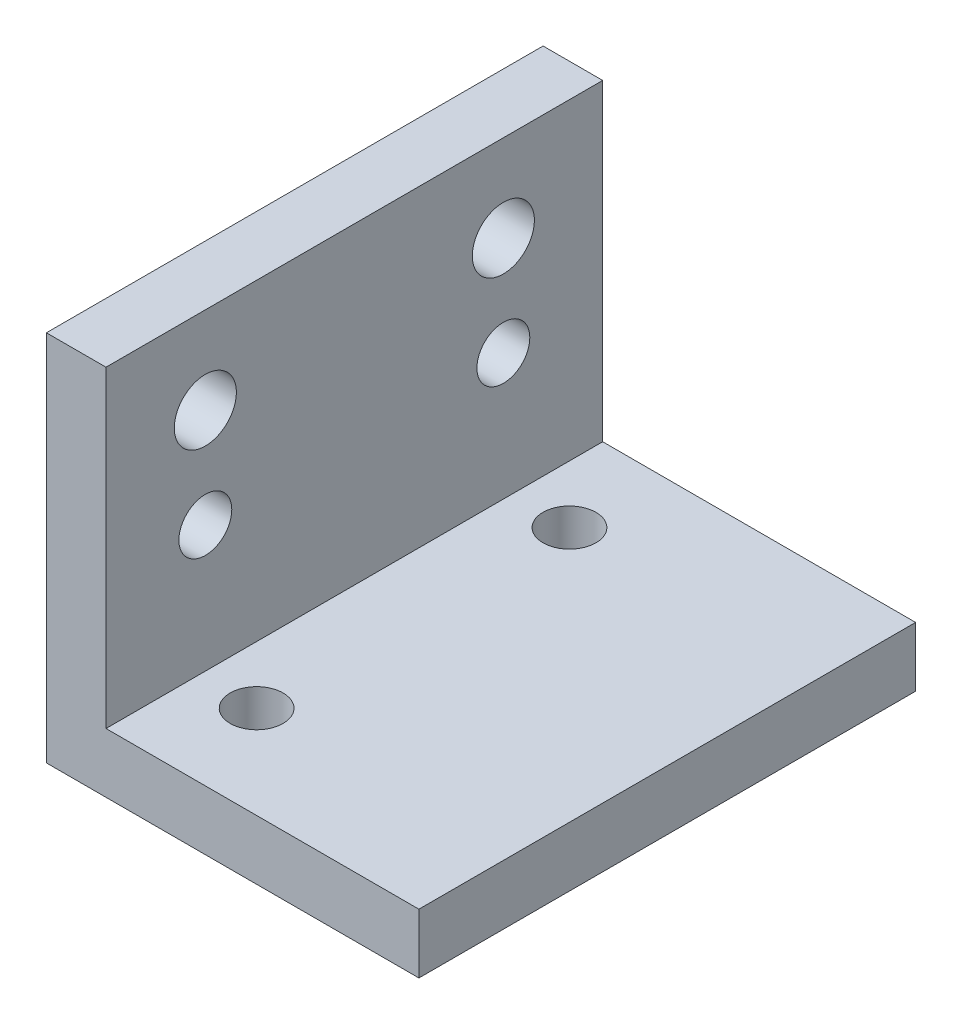
from build123d import *

# Parameters (mm, degrees)
BOSS_EXTRUDE1_DEPTH   = 25.4
F_6_32_TAPPED_HOLE1_D = 2.7051
F_6_32_TAPPED_HOLE2_D = 2.7051
SKETCH7_R             = 1.5875
CUT_EXTRUDE1_DEPTH    = 36.554556726


with BuildPart() as part:
    # Sketch1 → Boss-Extrude1 (new body)
    with BuildSketch(Plane.XY):
        Polygon((0, 0), (19.05, 0), (19.05, 3.048), (3.048, 3.048), (3.048, 19.05), (0, 19.05), align=None)
    extrude(amount=BOSS_EXTRUDE1_DEPTH)

    # 6-32 Tapped Hole1 (through all)
    with Locations(Plane(origin=(3.048, 0, 0), x_dir=(0, 0, -1), z_dir=(1, 0, 0))):
        with Locations((-20.32, 9.525), (-5.08, 9.525)):
            Hole(F_6_32_TAPPED_HOLE1_D / 2)

    # 6-32 Tapped Hole2 (through all)
    with Locations(Plane(origin=(0, 3.048, 0), x_dir=(1, 0, 0), z_dir=(0, 1, 0))):
        with Locations((6, -20.65), (6, -4.65)):
            Hole(F_6_32_TAPPED_HOLE2_D / 2)

    # Sketch7 → Cut-Extrude1 (cut, through all)
    with BuildSketch(Plane(origin=(3.048, 0, 0), x_dir=(0, 0, -1), z_dir=(1, 0, 0))):
        with Locations((-20.32, 14.605)):
            Circle(SKETCH7_R)
        with Locations((-5.08, 14.605)):
            Circle(SKETCH7_R)
    extrude(amount=-CUT_EXTRUDE1_DEPTH, mode=Mode.SUBTRACT)


solid = part.part
